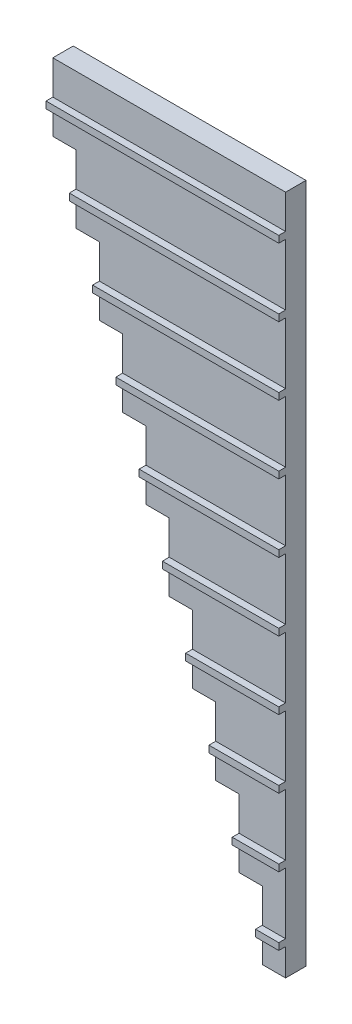
from build123d import *

# Parameters (mm, degrees)
BOSS_EXTRUDE2_DEPTH = 3
SKETCH2_W           = 34.2
SKETCH2_H           = 1
SKETCH2_W_2         = 30.78
SKETCH2_W_3         = 27.36
SKETCH2_W_4         = 23.94
SKETCH2_W_5         = 20.52
SKETCH2_W_6         = 17.1
SKETCH2_W_7         = 13.68
SKETCH2_W_8         = 10.26
SKETCH2_W_9         = 6.84
SKETCH2_W_10        = 3.42
BOSS_EXTRUDE3_DEPTH = 1


with BuildPart() as part:
    # Sketch1 → Boss-Extrude2 (new body)
    with BuildSketch(Plane.XY):
        Polygon((-27.552134831, 89.289101124), (-24.132134831, 89.289101124), (-20.712134831, 89.289101124), (-17.292134831, 89.289101124), (-13.872134831, 89.289101124), (-10.452134831, 89.289101124), (-7.032134831, 89.289101124), (-3.612134831, 89.289101124), (-0.192134831, 89.289101124), (3.227865169, 89.289101124), (6.647865169, 89.289101124), (6.647865169, 79.289101124), (6.647865169, 69.289101124), (6.647865169, 59.289101124), (6.647865169, 49.289101124), (6.647865169, 39.289101124), (6.647865169, 29.289101124), (6.647865169, 19.289101124), (6.647865169, 9.289101124), (6.647865169, -0.710898876), (6.647865169, -10.710898876), (3.227865169, -10.710898876), (3.227865169, -0.710898876), (-0.192134831, -0.710898876), (-0.192134831, 9.289101124), (-3.612134831, 9.289101124), (-3.612134831, 19.289101124), (-7.032134831, 19.289101124), (-7.032134831, 29.289101124), (-10.452134831, 29.289101124), (-10.452134831, 39.289101124), (-13.872134831, 39.289101124), (-13.872134831, 49.289101124), (-17.292134831, 49.289101124), (-17.292134831, 59.289101124), (-20.712134831, 59.289101124), (-20.712134831, 69.289101124), (-24.132134831, 69.289101124), (-24.132134831, 79.289101124), (-27.552134831, 79.289101124), align=None)
    extrude(amount=BOSS_EXTRUDE2_DEPTH)

    # Sketch2 → Boss-Extrude3 (add)
    with BuildSketch(Plane.XY.offset(3)):
        with Locations((-10.452134831, 83.789101124)):
            Rectangle(SKETCH2_W, SKETCH2_H)
        with Locations((-8.742134831, 73.789101124)):
            Rectangle(SKETCH2_W_2, SKETCH2_H)
        with Locations((-7.032134831, 63.789101124)):
            Rectangle(SKETCH2_W_3, SKETCH2_H)
        with Locations((-5.322134831, 53.789101124)):
            Rectangle(SKETCH2_W_4, SKETCH2_H)
        with Locations((-3.612134831, 43.789101124)):
            Rectangle(SKETCH2_W_5, SKETCH2_H)
        with Locations((-1.902134831, 33.789101124)):
            Rectangle(SKETCH2_W_6, SKETCH2_H)
        with Locations((-0.192134831, 23.789101124)):
            Rectangle(SKETCH2_W_7, SKETCH2_H)
        with Locations((1.517865169, 13.789101124)):
            Rectangle(SKETCH2_W_8, SKETCH2_H)
        with Locations((3.227865169, 3.789101124)):
            Rectangle(SKETCH2_W_9, SKETCH2_H)
        with Locations((4.937865169, -6.210898876)):
            Rectangle(SKETCH2_W_10, SKETCH2_H)
    extrude(amount=BOSS_EXTRUDE3_DEPTH)


solid = part.part
